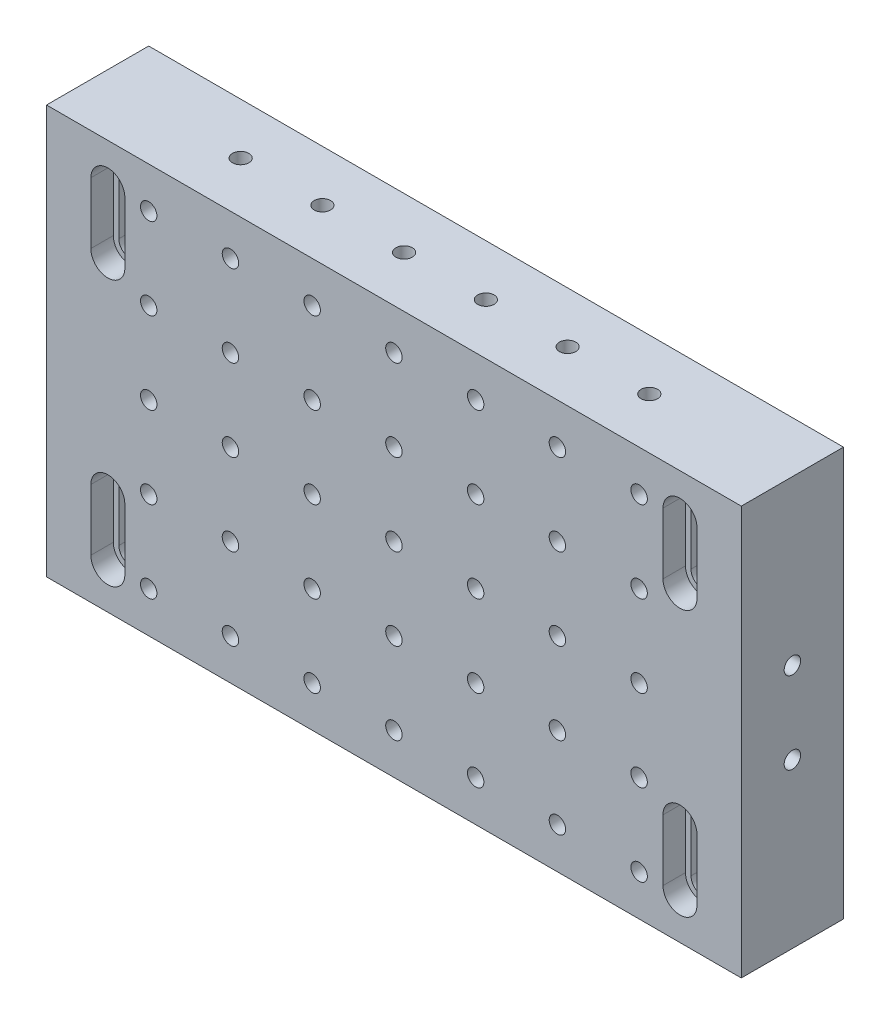
from build123d import *

# Parameters (mm, degrees)
SKETCH1_W               = 215.9
SKETCH1_H               = 127
BOSS_EXTRUDE1_DEPTH     = 31.75
CUT_EXTRUDE1_START      = -12.7
CUT_EXTRUDE1_DEPTH      = 19.05
LPATTERN1_COUNT         = 2
LPATTERN1_PITCH         = 82.55
LPATTERN1_COUNT_DIR2    = 2
LPATTERN1_PITCH_DIR2    = 177.8
F_1_4_20_TAPPED_HOLE1_D = 5.1054
LPATTERN7_COUNT         = 6
LPATTERN7_PITCH         = 25.4
LPATTERN10_COUNT        = 7
LPATTERN10_PITCH        = 25.4
LPATTERN10_COUNT_DIR2   = 5
LPATTERN10_PITCH_DIR2   = 25.4


with BuildPart() as part:
    # Sketch1 → Boss-Extrude1 (new body)
    with BuildSketch(Plane.XY):
        with Locations((107.95, 63.5)):
            Rectangle(SKETCH1_W, SKETCH1_H)
    extrude(amount=BOSS_EXTRUDE1_DEPTH)

    # Sketch2 → Cut-Extrude1 (cut)
    with BuildSketch(Plane.XZ.offset(CUT_EXTRUDE1_START)):
        Polygon((13.7668, 31.75), (13.7668, 24.765), (15.4813, 24.765), (15.4813, 0), (22.6187, 0), (22.6187, 24.765), (24.3332, 24.765), (24.3332, 31.75), align=None)
    cut_extrude1 = extrude(amount=-CUT_EXTRUDE1_DEPTH, mode=Mode.SUBTRACT)

    # Sketch4 → Cut-Revolve3 (revolve, cut)
    with BuildSketch(Plane.XZ.offset(-31.75)):
        Polygon((19.05, 0), (19.05, 31.75), (13.7668, 31.75), (13.7668, 24.765), (15.4813, 24.765), (15.4813, 0), align=None)
    cut_revolve3 = revolve(axis=Axis((19.05, 31.75, 0), (0, 0, 1)), mode=Mode.SUBTRACT)

    # Sketch6 → Cut-Revolve4 (revolve, cut)
    with BuildSketch(Plane(origin=(0, 12.7, 0), x_dir=(1, 0, 0), z_dir=(0, 1, 0))):
        Polygon((19.05, 0), (19.05, -31.75), (24.3332, -31.75), (24.3332, -24.765), (22.6187, -24.765), (22.6187, 0), align=None)
    cut_revolve4 = revolve(axis=Axis((19.05, 12.7, 0), (0, 0, 1)), mode=Mode.SUBTRACT)

    # LPattern1: Cut-Extrude1, Cut-Revolve3, Cut-Revolve4 2 × 2
    with Locations(*[(j * LPATTERN1_PITCH_DIR2, i * LPATTERN1_PITCH, 0) for i in range(LPATTERN1_COUNT) for j in range(LPATTERN1_COUNT_DIR2) if (i, j) != (0, 0)]):
        add(cut_extrude1, mode=Mode.SUBTRACT)
        add(cut_revolve3, mode=Mode.SUBTRACT)
        add(cut_revolve4, mode=Mode.SUBTRACT)

    # 1/4-20 Tapped Hole1 (through all)
    with Locations(Plane.XY.offset(31.75)):
        with Locations((31.75, 12.7)):
            f_1_4_20_tapped_hole1 = Hole(F_1_4_20_TAPPED_HOLE1_D / 2)

    # Sketch14 → 1/4-20 Tapped Hole3 (revolve, cut)
    with BuildSketch(Plane(origin=(215.9, 50.8, 15.875), x_dir=(0, 0, -1), z_dir=(0, 1, 0))):
        Polygon((0, 0), (0, 33.283816902), (2.5527, 31.75), (2.5527, 0), align=None)
    f_1_4_20_tapped_hole3 = revolve(axis=Axis((222.25, 50.8, 15.875), (-1, 0, 0)), mode=Mode.SUBTRACT)

    # Sketch22 → 1/4-20 Tapped Hole5 (revolve, cut)
    with BuildSketch(Plane(origin=(171.45, 127, 15.875), x_dir=(0, 0, 1), z_dir=(1, 0, 0))):
        Polygon((0, 0), (0, 33.283816902), (2.5527, 31.75), (2.5527, 0), align=None)
    f_1_4_20_tapped_hole5 = revolve(axis=Axis((171.45, 133.35, 15.875), (0, -1, 0)), mode=Mode.SUBTRACT)

    # LPattern7: 1/4-20 Tapped Hole5 ×6
    with Locations(*[(-i * LPATTERN7_PITCH, 0, 0) for i in range(1, LPATTERN7_COUNT)]):
        add(f_1_4_20_tapped_hole5, mode=Mode.SUBTRACT)

    # LPattern10: 1_4-20 Tapped Hole1 7 × 5
    with Locations(*[(i * LPATTERN10_PITCH, j * LPATTERN10_PITCH_DIR2, 0) for i in range(LPATTERN10_COUNT) for j in range(LPATTERN10_COUNT_DIR2) if (i, j) != (0, 0)]):
        add(f_1_4_20_tapped_hole1, mode=Mode.SUBTRACT)

    # Mirror1: 1/4-20 Tapped Hole3 across plane
    add(f_1_4_20_tapped_hole3.mirror(Plane(origin=(107.95, 0, 0), x_dir=(0, 0, 1), z_dir=(1, 0, 0))), mode=Mode.SUBTRACT)

    # Mirror2: 1/4-20 Tapped Hole3 across plane
    add(f_1_4_20_tapped_hole3.mirror(Plane.ZX.offset(63.5)), mode=Mode.SUBTRACT)

    # Mirror2 copy 1 sketch → Mirror2 copy 1 (revolve, cut)
    with BuildSketch(Plane(origin=(0, 76.2, 15.875), x_dir=(0, 0, -1), z_dir=(0, -1, 0))):
        Polygon((0, 0), (0, 33.283816902), (2.5527, 31.75), (2.5527, 0), align=None)
    revolve(axis=Axis((-6.35, 76.2, 15.875), (1, 0, 0)), mode=Mode.SUBTRACT)

    # Mirror3: 1/4-20 Tapped Hole5 across plane
    add(f_1_4_20_tapped_hole5.mirror(Plane.ZX.offset(63.5)), mode=Mode.SUBTRACT)

    # Mirror3 copy 1 sketch → Mirror3 copy 1 (revolve, cut)
    with BuildSketch(Plane(origin=(146.05, 0, 15.875), x_dir=(0, 0, 1), z_dir=(1, 0, 0))):
        Polygon((0, 0), (0, -33.283816902), (2.5527, -31.75), (2.5527, 0), align=None)
    revolve(axis=Axis((146.05, -6.35, 15.875), (0, -1, 0)), mode=Mode.SUBTRACT)

    # Mirror3 copy 2 sketch → Mirror3 copy 2 (revolve, cut)
    with BuildSketch(Plane(origin=(120.65, 0, 15.875), x_dir=(0, 0, 1), z_dir=(1, 0, 0))):
        Polygon((0, 0), (0, -33.283816902), (2.5527, -31.75), (2.5527, 0), align=None)
    revolve(axis=Axis((120.65, -6.35, 15.875), (0, -1, 0)), mode=Mode.SUBTRACT)

    # Mirror3 copy 3 sketch → Mirror3 copy 3 (revolve, cut)
    with BuildSketch(Plane(origin=(95.25, 0, 15.875), x_dir=(0, 0, 1), z_dir=(1, 0, 0))):
        Polygon((0, 0), (0, -33.283816902), (2.5527, -31.75), (2.5527, 0), align=None)
    revolve(axis=Axis((95.25, -6.35, 15.875), (0, -1, 0)), mode=Mode.SUBTRACT)

    # Mirror3 copy 4 sketch → Mirror3 copy 4 (revolve, cut)
    with BuildSketch(Plane(origin=(69.85, 0, 15.875), x_dir=(0, 0, 1), z_dir=(1, 0, 0))):
        Polygon((0, 0), (0, -33.283816902), (2.5527, -31.75), (2.5527, 0), align=None)
    revolve(axis=Axis((69.85, -6.35, 15.875), (0, -1, 0)), mode=Mode.SUBTRACT)

    # Mirror3 copy 5 sketch → Mirror3 copy 5 (revolve, cut)
    with BuildSketch(Plane(origin=(44.45, 0, 15.875), x_dir=(0, 0, 1), z_dir=(1, 0, 0))):
        Polygon((0, 0), (0, -33.283816902), (2.5527, -31.75), (2.5527, 0), align=None)
    revolve(axis=Axis((44.45, -6.35, 15.875), (0, -1, 0)), mode=Mode.SUBTRACT)


solid = part.part
